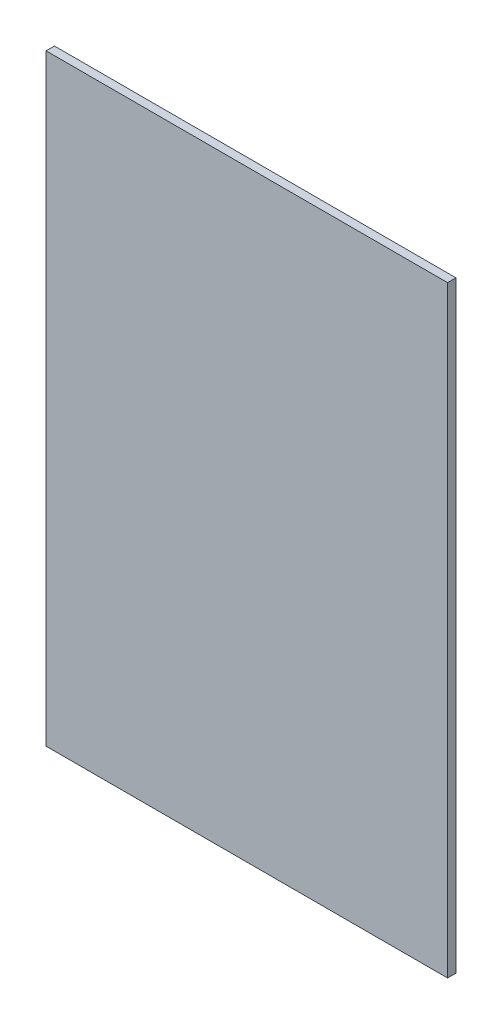
from build123d import *

# Parameters (mm, degrees)
SKETCH1_W           = 609.6
SKETCH1_H           = 914.4
BOSS_EXTRUDE1_DEPTH = 12.7


with BuildPart() as part:
    # Sketch1 → Boss-Extrude1 (new body)
    with BuildSketch(Plane.XY):
        Rectangle(SKETCH1_W, SKETCH1_H)
    extrude(amount=BOSS_EXTRUDE1_DEPTH)


solid = part.part
